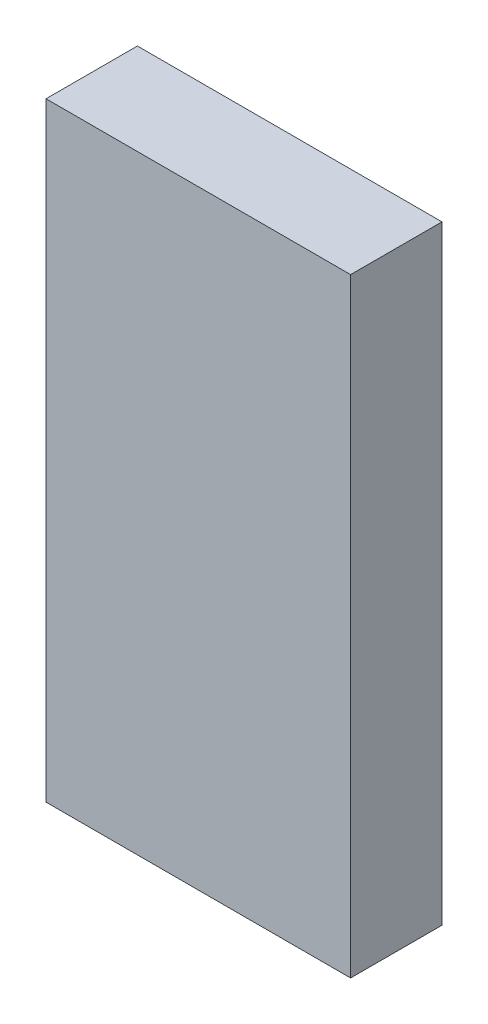
from build123d import *

# Parameters (mm, degrees)
SKETCH1_W           = 25.4
SKETCH1_H           = 50.8
BOSS_EXTRUDE1_DEPTH = 7.62


with BuildPart() as part:
    # Sketch1 → Boss-Extrude1 (new body)
    with BuildSketch(Plane.XY):
        Rectangle(SKETCH1_W, SKETCH1_H)
    extrude(amount=BOSS_EXTRUDE1_DEPTH)


solid = part.part
